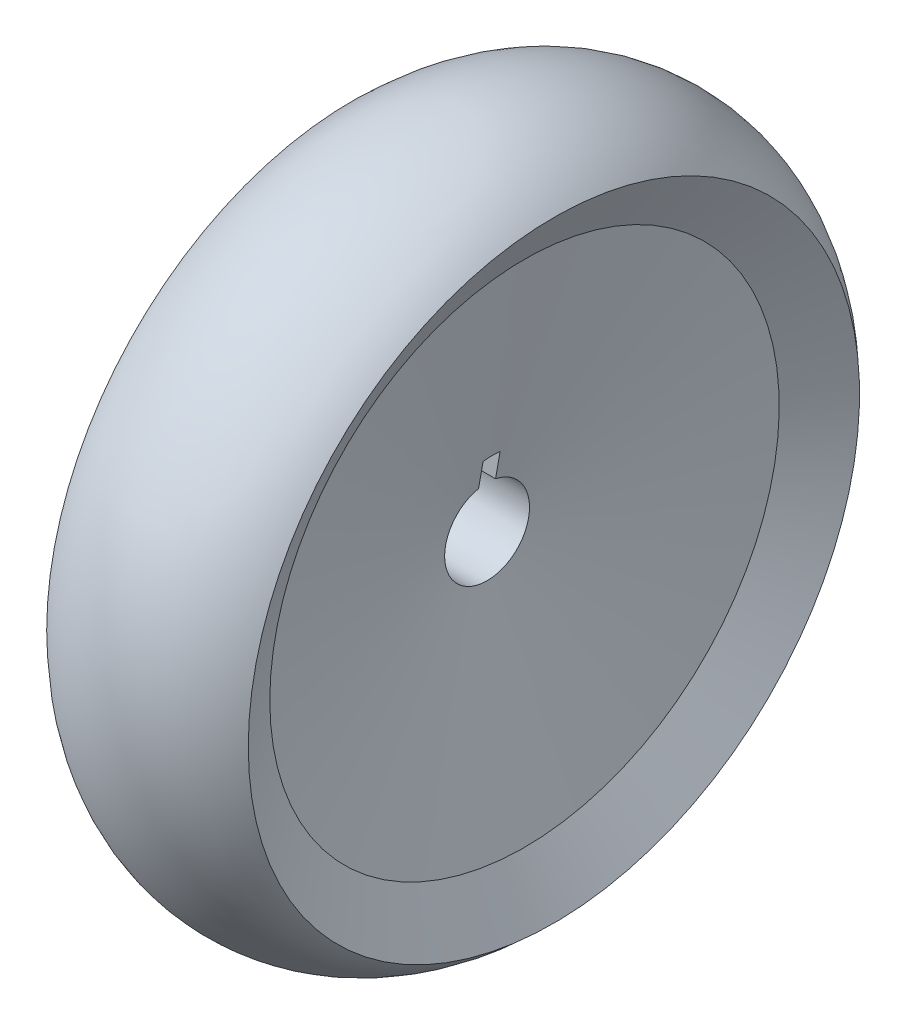
from build123d import *

# Parameters (mm, degrees)
CUT_EXTRUDE3_DEPTH      = 20
CUT_EXTRUDE3_DEPTH_BACK = 200.5


with BuildPart() as part:
    # Sketch1 → Revolve1 (revolve)
    with BuildSketch(Plane.XY):
        with BuildLine():
            Line((4, 0), (-4, 0))
            Line((-4, 0), (-8.408174518, 25))
            Line((-8.408174518, 25), (-11.872276133, 31))
            ThreePointArc((-11.872276133, 31), (0, 35.931604452), (11.872276133, 31))
            Line((11.872276133, 31), (8.408174518, 25))
            Line((8.408174518, 25), (4, 0))
        make_face()
    revolve(axis=Axis((-4, -5, 0), (1, 0, 0)))

    # Sketch2 → Cut-Extrude3 (cut, two sides)
    with BuildSketch(Plane(origin=(0, 0, 0), x_dir=(0, 0, -1), z_dir=(1, 0, 0))) as cut_extrude3_sk:
        with BuildLine():
            Line((-1, -5), (1, -5))
            Line((1, -5), (1, 2.937253933))
            ThreePointArc((1, 2.937253933), (0, 3), (-1, 2.937253933))
            Line((-1, 2.937253933), (-1, -5))
        make_face()
    extrude(amount=CUT_EXTRUDE3_DEPTH, mode=Mode.SUBTRACT)
    extrude(cut_extrude3_sk.sketch, amount=-CUT_EXTRUDE3_DEPTH_BACK, mode=Mode.SUBTRACT)


solid = part.part
